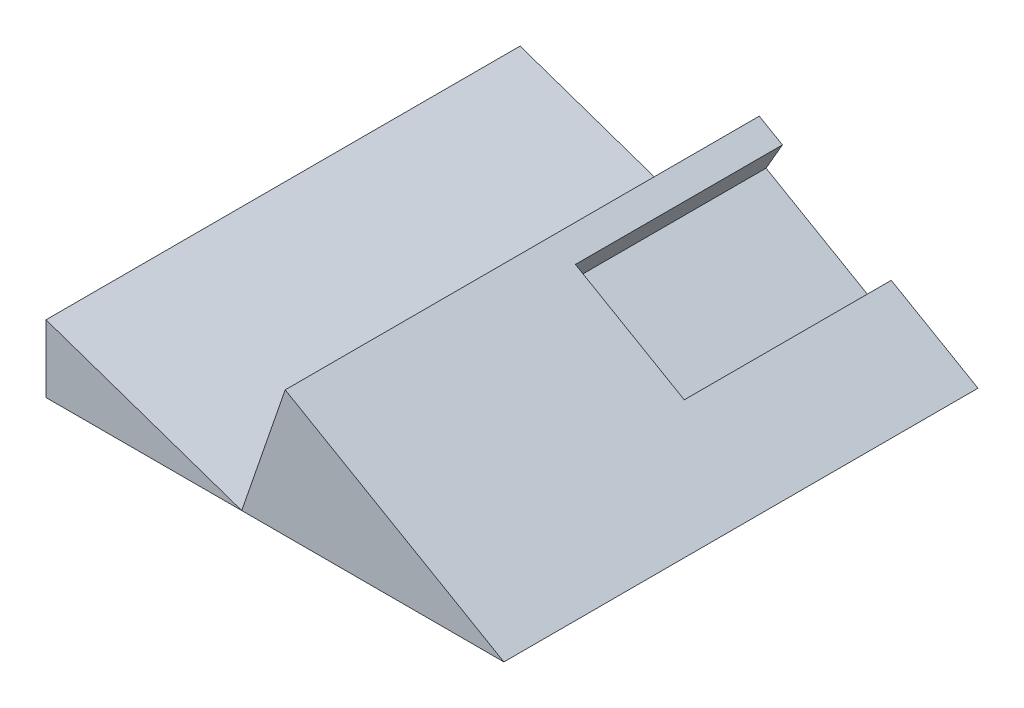
from build123d import *

# Parameters (mm, degrees)
SKETCH1_W               = 30
SKETCH1_H               = 103
BOSS_EXTRUDE1_DEPTH     = 2
BOSS_EXTRUDE2_DEPTH     = 103
SKETCH6_W               = 18.822447129
SKETCH6_H               = 70
CUT_EXTRUDE3_DEPTH      = 4.8963936
SKETCH7_W               = 32
SKETCH7_H               = 20.911223564
CUT_EXTRUDE4_DEPTH      = 73
SKETCH8_W               = 88.3630593
SKETCH8_H               = 30.379136557
CUT_EXTRUDE6_DEPTH      = 92.371324673
CUT_EXTRUDE6_DEPTH_BACK = 92.371324673


with BuildPart() as part:
    # Sketch1 → Boss-Extrude1 (new body)
    with BuildSketch(Plane(origin=(0, 0, 0), x_dir=(1, 0, 0), z_dir=(0, 1, 0))):
        Rectangle(SKETCH1_W, SKETCH1_H)
    extrude(amount=BOSS_EXTRUDE1_DEPTH)

    # Sketch2 → Boss-Extrude2 (add)
    with BuildSketch(Plane.XY.offset(51.5)):
        Polygon((0, 2), (15, 2), (-17.755200047, 20.911223564), (-24.26408807, 2), (-53.576484595, 12.088776436), (-53.576484595, 0), (-15, 0), (-15, 2), align=None)
    extrude(amount=-BOSS_EXTRUDE2_DEPTH)

    # Sketch6 → Cut-Extrude3 (cut)
    with BuildSketch(Plane(origin=(4.616025404, 7.995190528, 0), x_dir=(0.8660254037844382, -0.5000000000000009, 0), z_dir=(0.5000000000000009, 0.8660254037844382, 0))):
        with Locations((-12.420842507, 23.5)):
            Rectangle(SKETCH6_W, SKETCH6_H)
    extrude(amount=-CUT_EXTRUDE3_DEPTH, mode=Mode.SUBTRACT)

    # Sketch7 → Cut-Extrude4 (cut)
    with BuildSketch(Plane.ZY.offset(53.576484595)):
        with Locations((-35.5, 10.455611782)):
            Rectangle(SKETCH7_W, SKETCH7_H)
    extrude(amount=-CUT_EXTRUDE4_DEPTH, mode=Mode.SUBTRACT)

    # Sketch8 → Cut-Extrude6 (cut, two sides)
    with BuildSketch(Plane.XY.offset(51.5)) as cut_extrude6_sk:
        with Locations((-29.18152965, -13.189568279)):
            Rectangle(SKETCH8_W, SKETCH8_H)
    extrude(amount=CUT_EXTRUDE6_DEPTH, mode=Mode.SUBTRACT)
    extrude(cut_extrude6_sk.sketch, amount=-CUT_EXTRUDE6_DEPTH_BACK, mode=Mode.SUBTRACT)


with BuildPart() as cut_extrude6_piece_1:
    # of the separate pieces the step leaves, piece 1, a body of its own (cut_extrude6_pieces)
    add(part.part.solids().sort_by_distance((15, 2, 51.5))[0])


with BuildPart() as cut_extrude6_piece_2:
    # of the separate pieces the step leaves, piece 2, a body of its own (cut_extrude6_pieces)
    add(part.part.solids().sort_by_distance((-53.576484595, 2, 51.5))[0])


solid = Compound([cut_extrude6_piece_1.part, cut_extrude6_piece_2.part])
